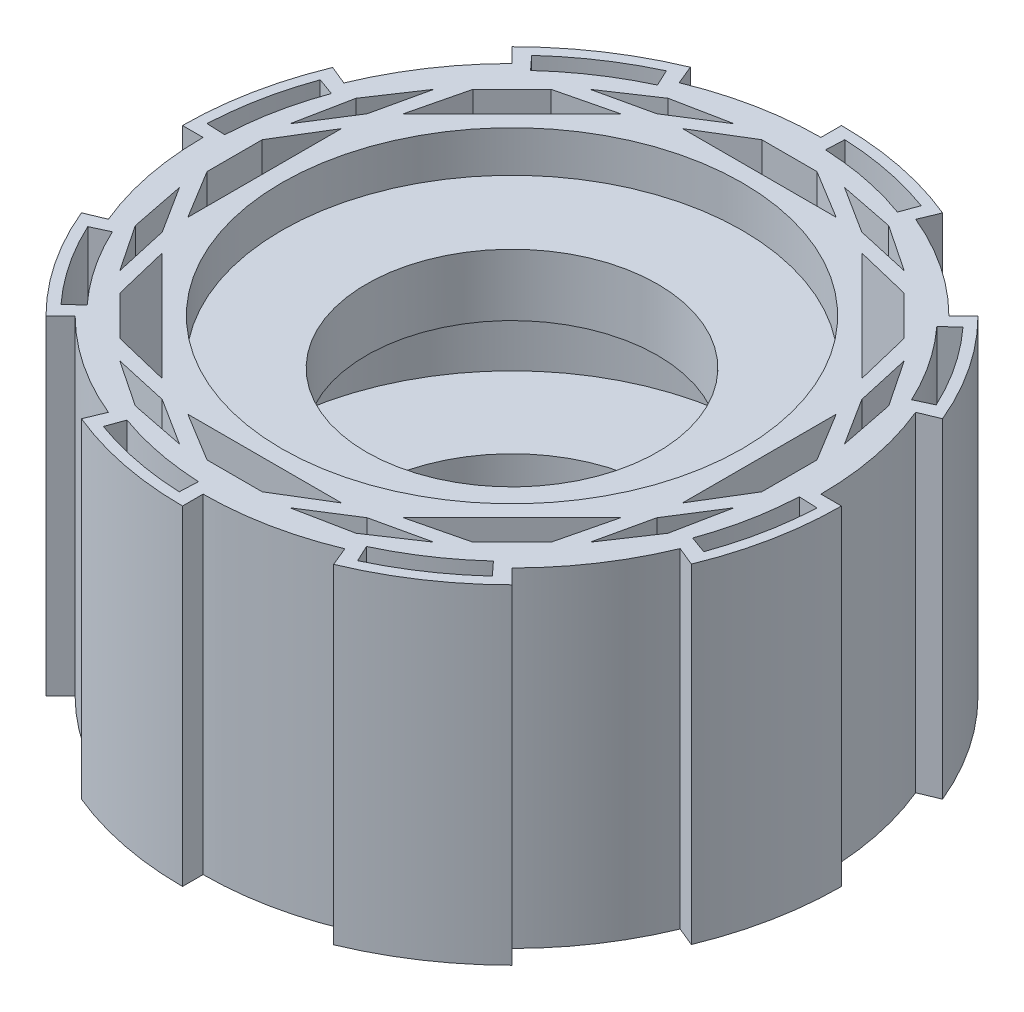
from build123d import *

# Parameters (mm, degrees)
SKETCH1_R                        = 45
BOSS_EXTRUDE1_DEPTH              = 80
SKETCH10_R                       = 60
SKETCH10_R_2                     = 35.34191
BOSS_EXTRUDE6_DEPTH              = 79
SKETCH11_R                       = 60
CUT_EXTRUDE6_DEPTH               = 10
SKETCH12_R                       = 60
CUT_EXTRUDE7_DEPTH               = 55
SKETCH14_R                       = 60
SKETCH14_R_2                     = 35.341911112
BOSS_EXTRUDE7_DEPTH              = 25
SKETCH15_R                       = 60
CUT_EXTRUDE8_DEPTH               = 10
SKETCH25_R                       = 58
SKETCH25_R_2                     = 49
OUTSIDE_CIRCLE_EXTENSION_1_DEPTH = 10
SKETCH26_R                       = 60
SKETCH26_R_2                     = 49
BOSS_EXTRUDE10_DEPTH             = 10
CUT_EXTRUDE14_DEPTH              = 112
CUT_EXTRUDE17_DEPTH              = 112
SKETCH29_R                       = 60
SKETCH29_R_2                     = 35.341911112
BOSS_EXTRUDE11_DEPTH             = 1
SKETCH30_R                       = 60
SKETCH30_R_2                     = 35.34191
BOSS_EXTRUDE12_DEPTH             = 1
SKETCH31_R                       = 55.914730937
CUT_EXTRUDE18_DEPTH              = 10
SKETCH32_R                       = 55.91473
CUT_EXTRUDE19_DEPTH              = 10
CUT_EXTRUDE20_DEPTH              = 66
CUT_EXTRUDE20_DEPTH_BACK         = 216


with BuildPart() as part:
    # Sketch1 → Boss-Extrude1 (new body)
    with BuildSketch(Plane(origin=(0, 0, 0), x_dir=(1, 0, 0), z_dir=(0, 1, 0))):
        with BuildLine():
            Line((-28.701257427, -69.290964938), (-30.603717804, -73.914900098))
            ThreePointArc((-30.603717804, -73.914900098), (-15.601410067, -78.463979022), (0, -80))
            Line((0, -80), (0, -75))
            ThreePointArc((0, -75), (14.631774151, -73.55889603), (28.701257427, -69.290964938))
            Line((28.701257427, -69.290964938), (30.614674589, -73.910362601))
            ThreePointArc((30.614674589, -73.910362601), (44.445618642, -66.517568984), (56.568542495, -56.568542495))
            Line((56.568542495, -56.568542495), (53.033008589, -53.033008589))
            ThreePointArc((53.033008589, -53.033008589), (62.409591507, -41.593784246), (69.358844501, -28.536830404))
            Line((69.358844501, -28.536830404), (73.982767468, -30.439285764))
            ThreePointArc((73.982767468, -30.439285764), (78.481276103, -15.514164537), (80, 0))
            Line((80, 0), (75, 0))
            ThreePointArc((75, 0), (73.55889603, 14.631774151), (69.290964938, 28.701257427))
            Line((69.290964938, 28.701257427), (73.910362601, 30.614674589))
            ThreePointArc((73.910362601, 30.614674589), (66.517568984, 44.445618642), (56.568542495, 56.568542495))
            Line((56.568542495, 56.568542495), (53.033008589, 53.033008589))
            ThreePointArc((53.033008589, 53.033008589), (41.680487796, 62.3517196), (28.729525087, 69.279249334))
            Line((28.729525087, 69.279249334), (30.64482676, 73.897865956))
            ThreePointArc((30.64482676, 73.897865956), (15.623231476, 78.459637), (0, 80))
            Line((0, 80), (0, 75))
            ThreePointArc((0, 75), (-14.631774151, 73.55889603), (-28.701257427, 69.290964938))
            Line((-28.701257427, 69.290964938), (-30.614674589, 73.910362601))
            ThreePointArc((-30.614674589, 73.910362601), (-44.445618642, 66.517568984), (-56.568542495, 56.568542495))
            Line((-56.568542495, 56.568542495), (-53.033008589, 53.033008589))
            ThreePointArc((-53.033008589, 53.033008589), (-62.409591507, 41.593784246), (-69.358844501, 28.536830404))
            Line((-69.358844501, 28.536830404), (-73.982767468, 30.439285764))
            ThreePointArc((-73.982767468, 30.439285764), (-78.481276103, 15.514164537), (-80, 0))
            Line((-80, 0), (-75, 0))
            ThreePointArc((-75, 0), (-73.55889603, -14.631774151), (-69.290964938, -28.701257427))
            Line((-69.290964938, -28.701257427), (-73.910362601, -30.614674589))
            ThreePointArc((-73.910362601, -30.614674589), (-66.517568984, -44.445618642), (-56.568542495, -56.568542495))
            Line((-56.568542495, -56.568542495), (-53.033008589, -53.033008589))
            ThreePointArc((-53.033008589, -53.033008589), (-41.667767476, -62.360220923), (-28.701257427, -69.290964938))
        make_face()
        Circle(SKETCH1_R, mode=Mode.SUBTRACT)
    extrude(amount=BOSS_EXTRUDE1_DEPTH)

    # Sketch10 → Boss-Extrude6 (add)
    with BuildSketch(Plane(origin=(0, 0, 0), x_dir=(1, 0, 0), z_dir=(0, 1, 0))):
        Circle(SKETCH10_R)
        Circle(SKETCH10_R_2, mode=Mode.SUBTRACT)
    extrude(amount=BOSS_EXTRUDE6_DEPTH)

    # Sketch11 → Cut-Extrude6 (cut)
    with BuildSketch(Plane(origin=(0, 79, 0), x_dir=(1, 0, 0), z_dir=(0, 1, 0))):
        Circle(SKETCH11_R)
    extrude(amount=-CUT_EXTRUDE6_DEPTH, mode=Mode.SUBTRACT)

    # Sketch12 → Cut-Extrude7 (cut)
    with BuildSketch(Plane.XZ):
        Circle(SKETCH12_R)
    extrude(amount=-CUT_EXTRUDE7_DEPTH, mode=Mode.SUBTRACT)

    # Sketch14 → Boss-Extrude7 (add)
    with BuildSketch(Plane.XZ):
        Circle(SKETCH14_R)
        Circle(SKETCH14_R_2, mode=Mode.SUBTRACT)
    extrude(amount=-BOSS_EXTRUDE7_DEPTH)

    # Sketch15 → Cut-Extrude8 (cut)
    with BuildSketch(Plane.XZ):
        Circle(SKETCH15_R)
    extrude(amount=-CUT_EXTRUDE8_DEPTH, mode=Mode.SUBTRACT)

    # Sketch25 → Outside Circle Extension 1 (add)
    with BuildSketch(Plane(origin=(0, 80, 0), x_dir=(1, 0, 0), z_dir=(0, 1, 0))):
        Circle(SKETCH25_R)
        Circle(SKETCH25_R_2, mode=Mode.SUBTRACT)
    extrude(amount=-OUTSIDE_CIRCLE_EXTENSION_1_DEPTH)

    # Sketch26 → Boss-Extrude10 (add)
    with BuildSketch(Plane.XZ):
        Circle(SKETCH26_R)
        Circle(SKETCH26_R_2, mode=Mode.SUBTRACT)
    extrude(amount=-BOSS_EXTRUDE10_DEPTH)

    # Sketch27 → Cut-Extrude14 (cut)
    with BuildSketch(Plane(origin=(0, 80, 0), x_dir=(1, 0, 0), z_dir=(0, 1, 0))):
        Polygon((-13.393920133, -67.335783638), (-24.874423104, -60.052169613), (-26.787840266, -64.671567276), align=None)
        Polygon((-24.874423104, -60.052169613), (-38.142657474, -57.084520979), (-26.787840266, -64.671567276), align=None)
        Polygon((-57.084520979, -38.142657474), (-60.052169613, -24.874423104), (-64.671567276, -26.787840266), align=None)
        Polygon((-60.052169613, -24.874423104), (-67.335783638, -13.393920133), (-64.671567276, -26.787840266), align=None)
        Polygon((-60.052169613, 24.874423104), (-57.084520979, 38.142657474), (-64.671567276, 26.787840266), align=None)
        Polygon((-67.335783638, 13.393920133), (-60.052169613, 24.874423104), (-64.671567276, 26.787840266), align=None)
        Polygon((-38.142657474, 57.084520979), (-24.874423104, 60.052169613), (-26.787840266, 64.671567276), align=None)
        Polygon((-24.874423104, 60.052169613), (-13.393920133, 67.335783638), (-26.787840266, 64.671567276), align=None)
        Polygon((26.787840266, 64.671567276), (13.393920133, 67.335783638), (24.874423104, 60.052169613), align=None)
        Polygon((26.787840266, 64.671567276), (24.874423104, 60.052169613), (38.142657474, 57.084520979), align=None)
        Polygon((64.671567276, 26.787840266), (57.084520979, 38.142657474), (60.052169613, 24.874423104), align=None)
        Polygon((67.335783638, 13.393920133), (64.671567276, 26.787840266), (60.052169613, 24.874423104), align=None)
        Polygon((57.084520979, -38.142657474), (64.671567276, -26.787840266), (60.052169613, -24.874423104), align=None)
        Polygon((64.671567276, -26.787840266), (67.335783638, -13.393920133), (60.052169613, -24.874423104), align=None)
        Polygon((26.787840266, -64.671567276), (38.142657474, -57.084520979), (24.874423104, -60.052169613), align=None)
        Polygon((13.393920133, -67.335783638), (26.787840266, -64.671567276), (24.874423104, -60.052169613), align=None)
    extrude(amount=-CUT_EXTRUDE14_DEPTH, mode=Mode.SUBTRACT)

    # Sketch28 → Cut-Extrude17 (cut)
    with BuildSketch(Plane(origin=(0, 80, 0), x_dir=(1, 0, 0), z_dir=(0, 1, 0))):
        Polygon((-60.052169613, -18.655817328), (-60.052169613, -12.437211552), (-67.335783638, 0), (-67.335783638, -6.696960066), align=None)
        Polygon((-60.052169613, -12.437211552), (-60.052169613, 0), (-60.052169613, 12.437211552), (-67.335783638, 0), align=None)
        Polygon((-67.335783638, 0), (-60.052169613, 12.437211552), (-60.052169613, 18.655817328), (-67.335783638, 6.696960066), align=None)
        Polygon((-51.257732986, 33.668859731), (-47.613589227, 47.613589227), (-52.349055103, 42.878123351), (-55.6549513, 29.271641417), align=None)
        Polygon((-42.463296358, 42.463296358), (-33.668859731, 51.257732986), (-47.613589227, 47.613589227), (-51.257732986, 33.668859731), align=None)
        Polygon((-33.668859731, 51.257732986), (-29.271641417, 55.6549513), (-42.878123351, 52.349055103), (-47.613589227, 47.613589227), align=None)
        Polygon((-6.696960066, 67.335783638), (-18.655817328, 60.052169613), (-12.437211552, 60.052169613), (0, 67.335783638), align=None)
        Polygon((0, 67.335783638), (-12.437211552, 60.052169613), (0, 60.052169613), (12.437211552, 60.052169613), align=None)
        Polygon((6.696960066, 67.335783638), (0, 67.335783638), (12.437211552, 60.052169613), (18.655817328, 60.052169613), align=None)
        Polygon((29.271641417, 55.6549513), (33.668859731, 51.257732986), (47.613589227, 47.613589227), (42.878123351, 52.349055103), align=None)
        Polygon((33.668859731, 51.257732986), (42.463296358, 42.463296358), (51.257732986, 33.668859731), (47.613589227, 47.613589227), align=None)
        Polygon((47.613589227, 47.613589227), (51.257732986, 33.668859731), (55.6549513, 29.271641417), (52.349055103, 42.878123351), align=None)
        Polygon((60.052169613, 18.655817328), (60.052169613, 12.437211552), (67.335783638, 0), (67.335783638, 6.696960066), align=None)
        Polygon((60.052169613, 12.437211552), (60.052169613, 0), (60.052169613, -12.437211552), (67.335783638, 0), align=None)
        Polygon((67.335783638, 0), (60.052169613, -12.437211552), (60.052169613, -18.671782095), (67.335783638, -6.696960066), align=None)
        Polygon((55.6549513, -29.271641417), (51.257732986, -33.668859731), (47.613589227, -47.613589227), (52.349055103, -42.878123351), align=None)
        Polygon((51.257732986, -33.668859731), (42.463296358, -42.463296358), (33.668859731, -51.257732986), (47.613589227, -47.613589227), align=None)
        Polygon((47.613589227, -47.613589227), (33.668859731, -51.257732986), (29.271641417, -55.6549513), (42.878123351, -52.349055103), align=None)
        Polygon((18.655817328, -60.052169613), (12.437211552, -60.052169613), (0, -67.335783638), (6.696960066, -67.335783638), align=None)
        Polygon((12.437211552, -60.052169613), (0, -60.052169613), (-12.437211552, -60.052169613), (0, -67.335783638), align=None)
        Polygon((0, -67.335783638), (-12.437211552, -60.052169613), (-18.655817328, -60.052169613), (-6.696960066, -67.335783638), align=None)
        Polygon((-29.271641417, -55.6549513), (-33.668859731, -51.257732986), (-47.613589227, -47.613589227), (-42.878123351, -52.349055103), align=None)
        Polygon((-33.668859731, -51.257732986), (-42.463296358, -42.463296358), (-51.257732986, -33.668859731), (-47.613589227, -47.613589227), align=None)
        Polygon((-47.613589227, -47.613589227), (-51.257732986, -33.668859731), (-55.6549513, -29.271641417), (-52.349055103, -42.878123351), align=None)
    extrude(amount=-CUT_EXTRUDE17_DEPTH, mode=Mode.SUBTRACT)

    # Sketch29 → Boss-Extrude11 (add)
    with BuildSketch(Plane(origin=(0, 25, 0), x_dir=(1, 0, 0), z_dir=(0, 1, 0))):
        Circle(SKETCH29_R)
        Circle(SKETCH29_R_2, mode=Mode.SUBTRACT)
    extrude(amount=BOSS_EXTRUDE11_DEPTH)

    # Sketch30 → Boss-Extrude12 (add)
    with BuildSketch(Plane.XZ.offset(-55)):
        Circle(SKETCH30_R)
        Circle(SKETCH30_R_2, mode=Mode.SUBTRACT)
    extrude(amount=BOSS_EXTRUDE12_DEPTH)

    # Sketch31 → Cut-Extrude18 (cut)
    with BuildSketch(Plane(origin=(0, 80, 0), x_dir=(1, 0, 0), z_dir=(0, 1, 0))):
        Circle(SKETCH31_R)
    extrude(amount=-CUT_EXTRUDE18_DEPTH, mode=Mode.SUBTRACT)

    # Sketch32 → Cut-Extrude19 (cut)
    with BuildSketch(Plane.XZ):
        Circle(SKETCH32_R)
    extrude(amount=-CUT_EXTRUDE19_DEPTH, mode=Mode.SUBTRACT)

    # Sketch34 → Cut-Extrude20 (cut, two sides)
    with BuildSketch(Plane(origin=(0, 80, 0), x_dir=(1, 0, 0), z_dir=(0, 1, 0))) as cut_extrude20_sk:
        with BuildLine():
            Line((-52.358240947, 57.138993446), (-49.318085156, 53.821245587))
            ThreePointArc((-49.318085156, 53.821245587), (-40.55662701, 60.697281698), (-30.851133107, 66.160468454))
            Line((-30.851133107, 66.160468454), (-32.752915195, 70.238853303))
            ThreePointArc((-32.752915195, 70.238853303), (-43.056692941, 64.438894777), (-52.358240947, 57.138993446))
        make_face()
        with BuildLine():
            Line((3.380502512, 77.42623696), (3.184215278, 72.930520175))
            ThreePointArc((3.184215278, 72.930520175), (14.256198722, 71.594418763), (24.995455531, 68.58736912))
            Line((24.995455531, 68.58736912), (26.53627121, 72.815357427))
            ThreePointArc((26.53627121, 72.815357427), (15.135005451, 76.007773136), (3.380502512, 77.42623696))
        make_face()
        with BuildLine():
            Line((57.138993446, 52.358240947), (53.821245587, 49.318085156))
            ThreePointArc((53.821245587, 49.318085156), (60.697281698, 40.55662701), (66.160468454, 30.851133107))
            Line((66.160468454, 30.851133107), (70.238853303, 32.752915195))
            ThreePointArc((70.238853303, 32.752915195), (64.438894777, 43.056692941), (57.138993446, 52.358240947))
        make_face()
        with BuildLine():
            ThreePointArc((72.930520175, -3.184215278), (71.614164444, -14.15667514), (68.656586928, -24.804698576))
            Line((68.656586928, -24.804698576), (72.888842086, -26.333755265))
            ThreePointArc((72.888842086, -26.333755265), (76.028736016, -15.029346854), (77.42623696, -3.380502512))
            Line((77.42623696, -3.380502512), (72.930520175, -3.184215278))
        make_face()
        with BuildLine():
            ThreePointArc((49.318085156, -53.821245587), (40.55662701, -60.697281698), (30.851133107, -66.160468454))
            Line((30.851133107, -66.160468454), (32.752915195, -70.238853303))
            ThreePointArc((32.752915195, -70.238853303), (43.056692941, -64.438894777), (52.358240947, -57.138993446))
            Line((52.358240947, -57.138993446), (49.318085156, -53.821245587))
        make_face()
        with BuildLine():
            ThreePointArc((-3.184215278, -72.930520175), (-14.15667514, -71.614164444), (-24.804698576, -68.656586928))
            Line((-24.804698576, -68.656586928), (-26.333755265, -72.888842086))
            ThreePointArc((-26.333755265, -72.888842086), (-15.029346854, -76.028736016), (-3.380502512, -77.42623696))
            Line((-3.380502512, -77.42623696), (-3.184215278, -72.930520175))
        make_face()
        with BuildLine():
            ThreePointArc((-53.821245587, -49.318085156), (-60.697281698, -40.55662701), (-66.160468454, -30.851133107))
            Line((-66.160468454, -30.851133107), (-70.238853303, -32.752915195))
            ThreePointArc((-70.238853303, -32.752915195), (-64.438894777, -43.056692941), (-57.138993446, -52.358240947))
            Line((-57.138993446, -52.358240947), (-53.821245587, -49.318085156))
        make_face()
        with BuildLine():
            ThreePointArc((-72.888842086, 26.333755265), (-76.028736016, 15.029346854), (-77.42623696, 3.380502512))
            Line((-77.42623696, 3.380502512), (-72.930520175, 3.184215278))
            ThreePointArc((-72.930520175, 3.184215278), (-71.614164444, 14.15667514), (-68.656586928, 24.804698576))
            Line((-68.656586928, 24.804698576), (-72.888842086, 26.333755265))
        make_face()
    extrude(amount=CUT_EXTRUDE20_DEPTH, mode=Mode.SUBTRACT)
    extrude(cut_extrude20_sk.sketch, amount=-CUT_EXTRUDE20_DEPTH_BACK, mode=Mode.SUBTRACT)


solid = part.part
